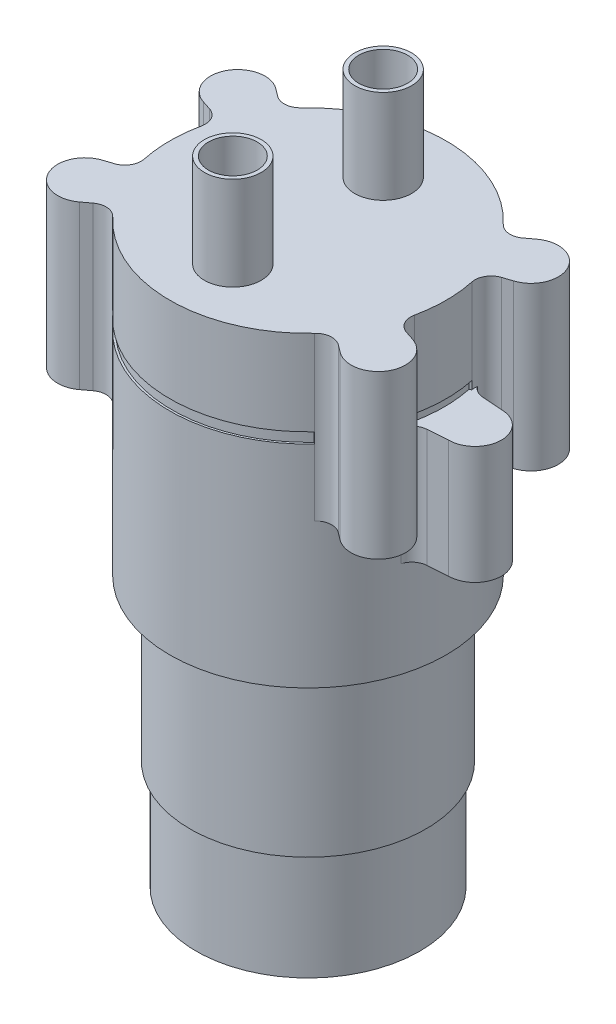
from build123d import *

# Parameters (mm, degrees)
RESSALTO_EXTRUS_O1_DEPTH = 20
RESSALTO_EXTRUS_O2_START = -11.5
RESSALTO_EXTRUS_O2_DEPTH = 14.5
ESBO_O4_R                = 3.5
ESBO_O4_R_2              = 3
RESSALTO_EXTRUS_O3_DEPTH = 11.5


with BuildPart() as part:
    # Esboço1 → Revolução1 (revolve)
    with BuildSketch(Plane.XY):
        Polygon((0, 52.008683422), (0, -22.491316578), (1.15, -22.491316578), (1.15, -21.491316578), (5, -21.491316578), (5, -18.991316578), (13.75, -18.991316578), (13.75, -5.591316578), (14.5, -5.591316578), (14.5, 14.208683422), (17, 14.208683422), (17, 40.208683422), (16.75, 40.208683422), (16.75, 41.508683422), (17, 41.508683422), (17, 52.008683422), align=None)
    revolve(axis=Axis((0, 52.008683422, 0), (0, -1, 0)))

    # Esboço2 → Ressalto-extrusão1 (add)
    with BuildSketch(Plane(origin=(0, 52.008683422, 0), x_dir=(1, 0, 0), z_dir=(0, 1, 0))):
        with BuildLine():
            Line((15.092560694, 11.367260519), (16.033467531, 12.075923108))
            ThreePointArc((16.033467531, 12.075923108), (21.020085445, 10.947420147), (19.086085546, 6.214606868))
            Line((19.086085546, 6.214606868), (17.966039096, 5.849909332))
            ThreePointArc((17.966039096, 5.849909332), (16.852954176, 4.947741706), (16.628916094, 3.532583974))
            Line((16.628916094, 3.532583974), (9.846019669, 0))
            Line((9.846019669, 0), (16.628916094, -3.532583974))
            ThreePointArc((16.628916094, -3.532583974), (16.852954176, -4.947741706), (17.966039096, -5.849909332))
            Line((17.966039096, -5.849909332), (19.086085546, -6.214606868))
            ThreePointArc((19.086085546, -6.214606868), (21.020085445, -10.947420147), (16.033467531, -12.075923108))
            Line((16.033467531, -12.075923108), (15.092560694, -11.367260519))
            ThreePointArc((15.092560694, -11.367260519), (13.715258298, -10.972415516), (12.427288325, -11.600107969))
            Line((12.427288325, -11.600107969), (0, -5.127881824))
            Line((0, -5.127881824), (-12.427288325, -11.600107969))
            ThreePointArc((-12.427288325, -11.600107969), (-13.715258298, -10.972415516), (-15.092560694, -11.367260519))
            Line((-15.092560694, -11.367260519), (-16.033467531, -12.075923108))
            ThreePointArc((-16.033467531, -12.075923108), (-21.020085445, -10.947420147), (-19.086085546, -6.214606868))
            Line((-19.086085546, -6.214606868), (-17.966039096, -5.849909332))
            ThreePointArc((-17.966039096, -5.849909332), (-16.852954176, -4.947741706), (-16.628916094, -3.532583974))
            Line((-16.628916094, -3.532583974), (-9.846019669, 0))
            Line((-9.846019669, 0), (-16.628916094, 3.532583974))
            ThreePointArc((-16.628916094, 3.532583974), (-16.852954176, 4.947741706), (-17.966039096, 5.849909332))
            Line((-17.966039096, 5.849909332), (-19.086085546, 6.214606868))
            ThreePointArc((-19.086085546, 6.214606868), (-21.020085445, 10.947420147), (-16.033467531, 12.075923108))
            Line((-16.033467531, 12.075923108), (-15.092560694, 11.367260519))
            ThreePointArc((-15.092560694, 11.367260519), (-13.715258298, 10.972415516), (-12.427288325, 11.600107969))
            Line((-12.427288325, 11.600107969), (0, 5.127881824))
            Line((0, 5.127881824), (12.427288325, 11.600107969))
            ThreePointArc((12.427288325, 11.600107969), (13.715258298, 10.972415516), (15.092560694, 11.367260519))
        make_face()
    extrude(amount=-RESSALTO_EXTRUS_O1_DEPTH)

    # Esboço3 → Ressalto-extrusão2 (add)
    with BuildSketch(Plane(origin=(0, 52.008683422, 0), x_dir=(1, 0, 0), z_dir=(0, 1, 0)).offset(RESSALTO_EXTRUS_O2_START)):
        with BuildLine():
            Line((-20.55, -3.25), (-18.065620285, -3.429043833))
            ThreePointArc((-18.065620285, -3.429043833), (-16.957055718, -3.864486935), (-16.292605909, -4.852936501))
            Line((-16.292605909, -4.852936501), (-16.292605909, 4.852936501))
            ThreePointArc((-16.292605909, 4.852936501), (-16.957055718, 3.864486935), (-18.065620285, 3.429043833))
            Line((-18.065620285, 3.429043833), (-20.55, 3.25))
            ThreePointArc((-20.55, 3.25), (-23.8, 0), (-20.55, -3.25))
        make_face()
        with BuildLine():
            Line((16.292605909, -4.852936501), (16.292605909, 4.852936501))
            ThreePointArc((16.292605909, 4.852936501), (16.957055718, 3.864486935), (18.065620285, 3.429043833))
            Line((18.065620285, 3.429043833), (20.55, 3.25))
            ThreePointArc((20.55, 3.25), (23.8, 0), (20.55, -3.25))
            Line((20.55, -3.25), (18.065620285, -3.429043833))
            ThreePointArc((18.065620285, -3.429043833), (16.957055718, -3.864486935), (16.292605909, -4.852936501))
        make_face()
    extrude(amount=-RESSALTO_EXTRUS_O2_DEPTH)

    # Esboço4 → Ressalto-extrusão3 (add)
    with BuildSketch(Plane(origin=(0, 52.008683422, 0), x_dir=(1, 0, 0), z_dir=(0, 1, 0))):
        with Locations((0, -9.25)):
            Circle(ESBO_O4_R)
        with Locations((0, -9.25)):
            Circle(ESBO_O4_R_2, mode=Mode.SUBTRACT)
        with Locations((0, 9.25)):
            Circle(ESBO_O4_R)
        with Locations((0, 9.25)):
            Circle(ESBO_O4_R_2, mode=Mode.SUBTRACT)
    extrude(amount=RESSALTO_EXTRUS_O3_DEPTH)


solid = part.part
